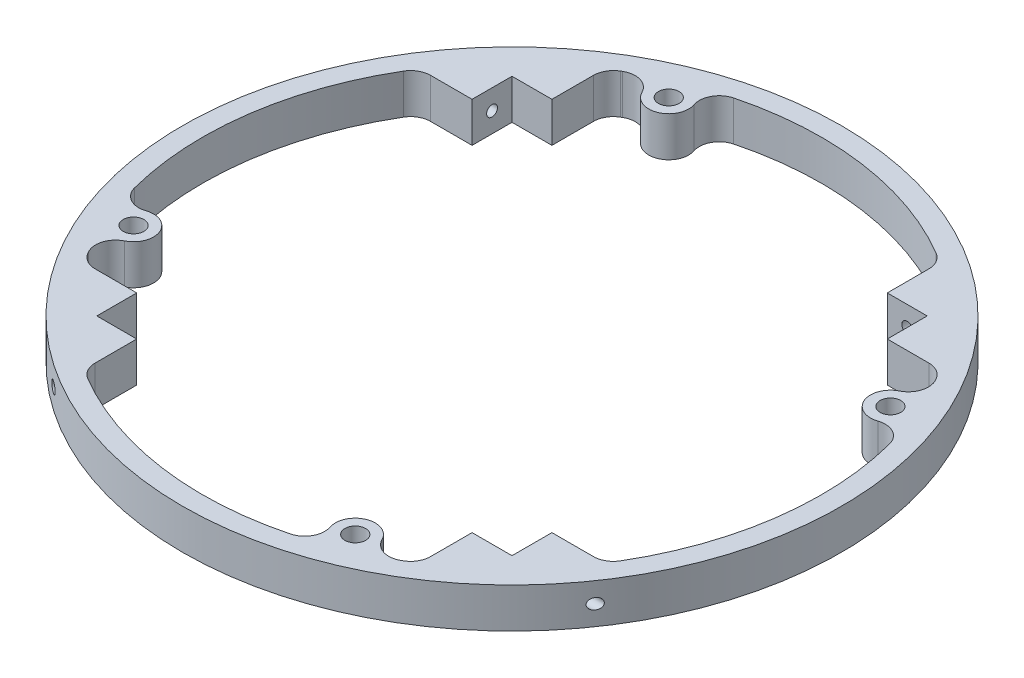
from build123d import *

# Parameters (mm, degrees)
SKETCH1_R                  = 82.55
BOSS_EXTRUDE1_DEPTH        = 10
FILLET1_R                  = 5
F_6_0_204_DIAMETER_HOLE1_D = 5.1816
F_6_32_TAPPED_HOLE2_D      = 2.7051
F_6_32_TAPPED_HOLE2_DEPTH  = 30.55
CIRPATTERN1_COUNT          = 4


with BuildPart() as part:
    # Sketch1 → Boss-Extrude1 (new body)
    with BuildSketch(Plane(origin=(0, 0, 0), x_dir=(1, 0, 0), z_dir=(0, 1, 0))):
        Circle(SKETCH1_R)
        with BuildLine():
            Line((-42, 52), (-52, 52))
            Line((-52, 52), (-52, 42))
            Line((-52, 42), (-65.192043226, 42))
            ThreePointArc((-65.192043226, 42), (-74.396389201, 21.890175283), (-77.55, 0))
            ThreePointArc((-77.55, 0), (-76.508304446, -12.66814315), (-73.411203073, -24.995954941))
            Line((-73.411203073, -24.995954941), (-68.940877246, -23.144285356))
            ThreePointArc((-68.940877246, -23.144285356), (-62.408062421, -25.850265856), (-65.114042922, -32.383080681))
            Line((-65.114042922, -32.383080681), (-69.584368749, -34.234750266))
            ThreePointArc((-69.584368749, -34.234750266), (-67.499963571, -38.180589544), (-65.192043226, -42))
            Line((-65.192043226, -42), (-52, -42))
            Line((-52, -42), (-52, -52))
            Line((-52, -52), (-42, -52))
            Line((-42, -52), (-42, -65.192043226))
            ThreePointArc((-42, -65.192043226), (-21.890175283, -74.396389201), (0, -77.55))
            ThreePointArc((0, -77.55), (12.66814315, -76.508304446), (24.995954941, -73.411203073))
            Line((24.995954941, -73.411203073), (23.144285356, -68.940877246))
            ThreePointArc((23.144285356, -68.940877246), (25.850265856, -62.408062421), (32.383080681, -65.114042922))
            Line((32.383080681, -65.114042922), (34.234750266, -69.584368749))
            ThreePointArc((34.234750266, -69.584368749), (38.180589544, -67.499963571), (42, -65.192043226))
            Line((42, -65.192043226), (42, -52))
            Line((42, -52), (52, -52))
            Line((52, -52), (52, -42))
            Line((52, -42), (65.192043226, -42))
            ThreePointArc((65.192043226, -42), (74.396389201, -21.890175283), (77.55, 0))
            ThreePointArc((77.55, 0), (76.508304446, 12.66814315), (73.411203073, 24.995954941))
            Line((73.411203073, 24.995954941), (68.940877246, 23.144285356))
            ThreePointArc((68.940877246, 23.144285356), (62.408062421, 25.850265856), (65.114042922, 32.383080681))
            Line((65.114042922, 32.383080681), (69.584368749, 34.234750266))
            ThreePointArc((69.584368749, 34.234750266), (67.499963571, 38.180589544), (65.192043226, 42))
            Line((65.192043226, 42), (52, 42))
            Line((52, 42), (52, 52))
            Line((52, 52), (42, 52))
            Line((42, 52), (42, 65.192043226))
            ThreePointArc((42, 65.192043226), (21.890175283, 74.396389201), (0, 77.55))
            ThreePointArc((0, 77.55), (-12.66814315, 76.508304446), (-24.995954941, 73.411203073))
            Line((-24.995954941, 73.411203073), (-23.144285356, 68.940877246))
            ThreePointArc((-23.144285356, 68.940877246), (-25.850265856, 62.408062421), (-32.383080681, 65.114042922))
            Line((-32.383080681, 65.114042922), (-34.234750266, 69.584368749))
            ThreePointArc((-34.234750266, 69.584368749), (-38.180589544, 67.499963571), (-42, 65.192043226))
            Line((-42, 65.192043226), (-42, 52))
        make_face(mode=Mode.SUBTRACT)
    extrude(amount=BOSS_EXTRUDE1_DEPTH)

    # Fillet1
    fillet1_edges = [part.edges().sort_by_distance(p)[0] for p in [
        (-73.411203073, 5, 24.995954941),
        (-69.584368749, 5, 34.234750266),
        (-42, 5, 65.192043226),
        (-65.192043226, 5, 42),
        (24.995954941, 5, 73.411203073),
        (34.234750266, 5, 69.584368749),
        (42, 5, 65.192043226),
        (65.192043226, 5, 42),
        (73.411203073, 5, -24.995954941),
        (69.584368749, 5, -34.234750266),
        (65.192043226, 5, -42),
        (42, 5, -65.192043226),
        (-34.234750266, 5, -69.584368749),
        (-24.995954941, 5, -73.411203073),
        (-42, 5, -65.192043226),
        (-65.192043226, 5, -42),
    ]]
    fillet(fillet1_edges, radius=FILLET1_R)

    # 6 _0.204_ Diameter Hole1 (through all)
    with Locations(Plane(origin=(0, 10, 0), x_dir=(1, 0, 0), z_dir=(0, 1, 0))):
        with Locations((67.027460084, 27.763683018)):
            f_6_0_204_diameter_hole1 = Hole(F_6_0_204_DIAMETER_HOLE1_D / 2)

    # 6-32 Tapped Hole2
    with Locations(Plane.XY.offset(-52)):
        with Locations((47, 5)):
            f_6_32_tapped_hole2 = Hole(F_6_32_TAPPED_HOLE2_D / 2, depth=F_6_32_TAPPED_HOLE2_DEPTH)

    # CirPattern1: 6 _0.204_ Diameter Hole1, 6-32 Tapped Hole2 ×4 about axis
    cirpattern1_axis = Axis((0, 0, 0), (0, 1, 0))
    for i in range(1, CIRPATTERN1_COUNT):
        add(f_6_0_204_diameter_hole1.rotate(cirpattern1_axis, i * 360 / CIRPATTERN1_COUNT), mode=Mode.SUBTRACT)
        add(f_6_32_tapped_hole2.rotate(cirpattern1_axis, i * 360 / CIRPATTERN1_COUNT), mode=Mode.SUBTRACT)


solid = part.part
